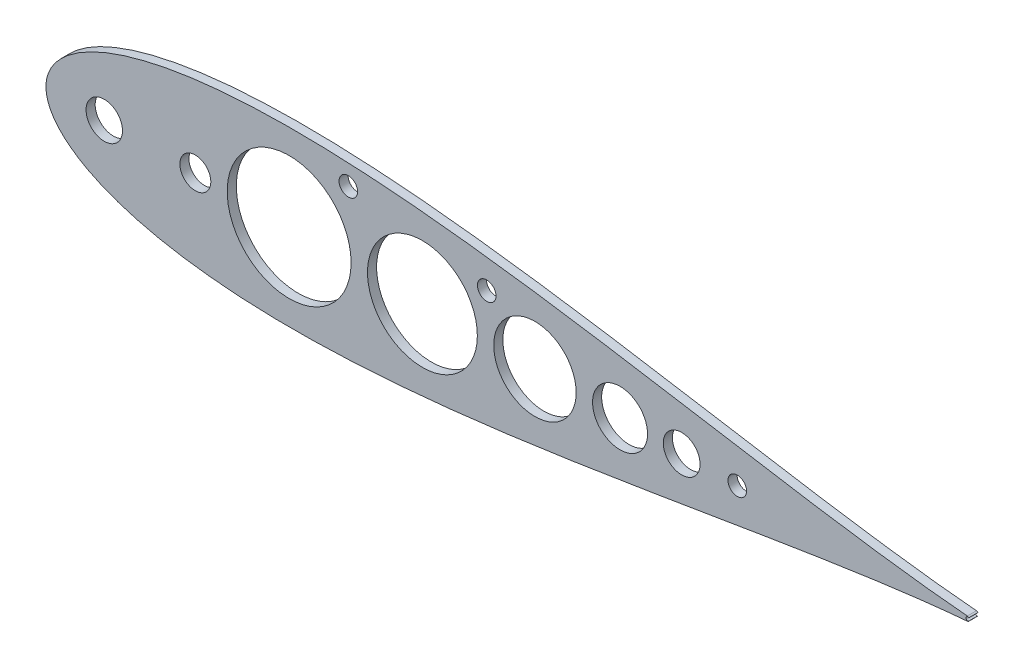
from build123d import *

# Parameters (mm, degrees)
BOSS_EXTRUDE1_DEPTH = 6.35
CUT_EXTRUDE2_START  = -7.3500001
CUT_EXTRUDE2_DEPTH  = 8.3500002
SKETCH4_R           = 6.477
CUT_EXTRUDE3_DEPTH  = 7.3500001


with BuildPart() as part:
    # Sketch2 → Boss-Extrude1 (new body)
    with BuildSketch(Plane.XY):
        with BuildLine():
            ThreePointArc((642.510849283, -1.582039112), (643.111845681, -1.408373102), (643.599082689, -1.016))
            ThreePointArc((643.599082689, -1.016), (642.269121423, -1.135922533), (641.567082689, 0))
            Line((641.567082689, 0), (473.360965279, 0))
            Line((473.360965279, 0), (460.660965279, 0))
            Line((460.660965279, 0), (114.935, 0))
            ThreePointArc((114.935, 0), (104.14, -10.795), (93.345, 0))
            Line((93.345, 0), (53.34, 0))
            ThreePointArc((53.34, 0), (40.64, -12.7), (27.94, 0))
            Line((27.94, 0), (0, 0))
            add(Edge.make_bspline(
                [(0, 0), (0, -1.007496172), (0.154611582, -3.513796615), (1.106333228, -7.923389435), (3.463136343, -13.420354421), (7.689616489, -19.513207632), (13.932423524, -25.726412106), (22.129107375, -31.731455339), (32.141645239, -37.332204029), (43.82045433, -42.41500246), (57.023709725, -46.912543066), (71.619696083, -50.784752003), (87.485018636, -54.008935199), (104.502313427, -56.574303932), (122.558104573, -58.481758104), (141.542033828, -59.739895824), (161.345829027, -60.366961324), (181.863132616, -60.387506142), (202.989192599, -59.8341217), (224.620860897, -58.745176641), (246.65655865, -57.164603829), (268.996310773, -55.141201012), (291.541767704, -52.727712704), (314.196207315, -49.979843895), (336.86454415, -46.955447457), (359.453314895, -43.713502532), (381.870662856, -40.313266856), (404.02631566, -36.813220545), (425.831595832, -33.270324121), (447.199424328, -29.739007432), (468.044367735, -26.27043606), (488.282710288, -22.911672601), (507.832591566, -19.705111663), (526.614143658, -16.687720753), (544.549749946, -13.890665375), (561.564270734, -11.338919625), (577.585454095, -9.050636147), (592.543922516, -7.037634907), (606.374988512, -5.304428983), (619.014124193, -3.849253664), (630.413817462, -2.663385493), (638.093728429, -1.953546407), (641.993392355, -1.625070631), (642.510849283, -1.582039112)],
                knots=[0.5, 0.5, 0.5, 0.5, 0.502166769, 0.505390167, 0.509655974, 0.514947682, 0.521244711, 0.528520886, 0.536744945, 0.54588136, 0.555890751, 0.566730119, 0.57835299, 0.590709588, 0.603747039, 0.617409572, 0.631638768, 0.646373793, 0.661551658, 0.677107483, 0.692974771, 0.709085713, 0.725371443, 0.741762353, 0.758188398, 0.774579367, 0.790865214, 0.806976332, 0.822843867, 0.838400002, 0.853578262, 0.868313774, 0.882543568, 0.896206835, 0.909245173, 0.92160287, 0.933227116, 0.944068236, 0.954079898, 0.963219316, 0.971447445, 0.978729112, 0.979842958, 0.979842958, 0.979842958, 0.979842958], degree=3))
        make_face()
    boss_extrude1 = extrude(amount=BOSS_EXTRUDE1_DEPTH)

    # Sketch3 → Cut-Extrude2 (cut)
    with BuildSketch(Plane.XY.offset(6.35).offset(CUT_EXTRUDE2_START)):
        with BuildLine():
            ThreePointArc((212.767950148, 0), (169.566475074, 43.201475074), (126.365, 0))
            Line((126.365, 0), (212.767950148, 0))
        make_face()
        with BuildLine():
            Line((212.767950148, 0), (126.365, 0))
            ThreePointArc((126.365, 0), (169.566475074, -43.201475074), (212.767950148, 0))
        make_face()
        with BuildLine():
            ThreePointArc((300.809151759, 0), (262.503550953, 38.305600806), (224.197950148, 0))
            Line((224.197950148, 0), (300.809151759, 0))
        make_face()
        with BuildLine():
            Line((300.809151759, 0), (224.197950148, 0))
            ThreePointArc((224.197950148, 0), (262.503550953, -38.305600806), (300.809151759, 0))
        make_face()
        with BuildLine():
            ThreePointArc((369.720663748, 0), (340.979907754, 28.740755995), (312.239151759, 0))
            Line((312.239151759, 0), (369.720663748, 0))
        make_face()
        with BuildLine():
            Line((369.720663748, 0), (312.239151759, 0))
            ThreePointArc((312.239151759, 0), (340.979907754, -28.740755995), (369.720663748, 0))
        make_face()
        with BuildLine():
            ThreePointArc((381.150663748, 0), (400.327663748, -19.177), (419.504663748, 0))
            Line((419.504663748, 0), (381.150663748, 0))
        make_face()
        with BuildLine():
            Line((381.150663748, 0), (419.504663748, 0))
            ThreePointArc((419.504663748, 0), (400.327663748, 19.177), (381.150663748, 0))
        make_face()
        with BuildLine():
            ThreePointArc((430.474866123, 0), (443.301866123, -12.827), (456.128866123, 0))
            Line((456.128866123, 0), (430.474866123, 0))
        make_face()
        with BuildLine():
            Line((430.474866123, 0), (456.128866123, 0))
            ThreePointArc((456.128866123, 0), (443.301866123, 12.827), (430.474866123, 0))
        make_face()
        with BuildLine():
            ThreePointArc((475.605534569, 0), (482.082534569, -6.477), (488.559534569, 0))
            Line((488.559534569, 0), (475.605534569, 0))
        make_face()
        with BuildLine():
            Line((475.605534569, 0), (488.559534569, 0))
            ThreePointArc((488.559534569, 0), (482.082534569, 6.477), (475.605534569, 0))
        make_face()
    cut_extrude2 = extrude(amount=CUT_EXTRUDE2_DEPTH, mode=Mode.SUBTRACT)

    # Mirror1: Boss-Extrude1, Cut-Extrude2 across plane
    add(boss_extrude1.mirror(Plane.ZX))
    add(cut_extrude2.mirror(Plane.ZX), mode=Mode.SUBTRACT)

    # Sketch4 → Cut-Extrude3 (cut, through all)
    with BuildSketch(Plane.XY.offset(6.35)):
        with Locations((210.82, 45.212)):
            Circle(SKETCH4_R)
        with Locations((307.34, 30.48)):
            Circle(SKETCH4_R)
    extrude(amount=-CUT_EXTRUDE3_DEPTH, mode=Mode.SUBTRACT)


solid = part.part
